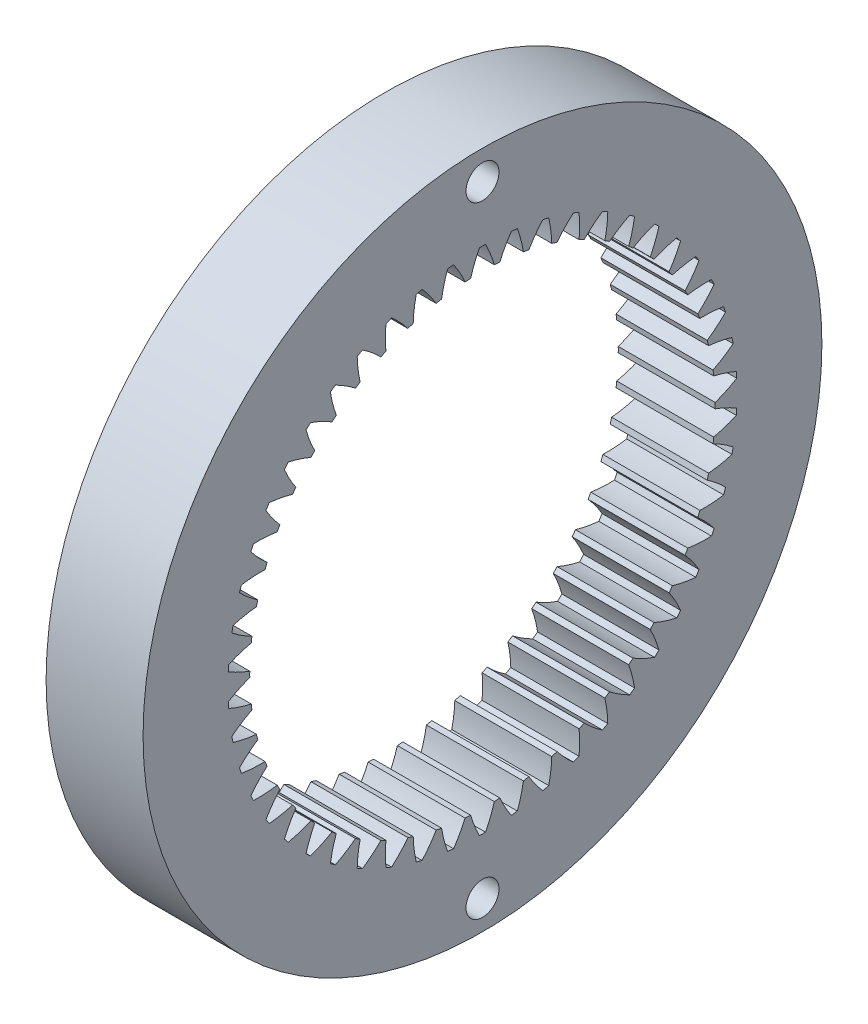
from build123d import *

# Parameters (mm, degrees)
BASPROSKE_W           = 10
BASPROSKE_H           = 11
TOOTHCUT_DEPTH        = 51.497524692
TEETHCUTS_COUNT       = 50
CROQUIS2_R            = 1.7
CORTAR_EXTRUIR1_DEPTH = 10


with BuildPart() as part:
    # BasProSke → Base-Revolve (revolve)
    with BuildSketch(Plane(origin=(0, 0, 0), x_dir=(1, 0, 0), z_dir=(0, 1, 0)), mode=Mode.PRIVATE) as base_revolve_sk:
        with Locations((5, 29.5)):
            Rectangle(BASPROSKE_W, BASPROSKE_H)
    revolve(base_revolve_sk.sketch.rotate(Axis((-10, 0, 0), (1, 0, 0)), 180), axis=Axis((-10, 0, 0), (1, 0, 0)))

    # TooCutSke → ToothCut (cut, through all)
    with BuildSketch(Plane(origin=(0, 0, 0), x_dir=(0, 0, -1), z_dir=(1, 0, 0))):
        with BuildLine():
            ThreePointArc((1.228249008, 23.943116955), (0.8277994, 25.118901547), (0.312635126, 26.249138277))
            ThreePointArc((0.312635126, 26.249138277), (0, 26.251), (-0.312635126, 26.249138277))
            ThreePointArc((-0.312635126, 26.249138277), (-0.8277994, 25.118901547), (-1.228249008, 23.943116955))
            ThreePointArc((-1.228249008, 23.943116955), (0, 23.9746), (1.228249008, 23.943116955))
        make_face()
    toothcut = extrude(amount=TOOTHCUT_DEPTH, mode=Mode.SUBTRACT)

    # TeethCuts: ToothCut ×50 about axis
    teethcuts_axis = Axis((0, 0, 0), (1, 0, 0))
    for i in range(1, TEETHCUTS_COUNT):
        add(toothcut.rotate(teethcuts_axis, i * 360 / TEETHCUTS_COUNT), mode=Mode.SUBTRACT)

    # Croquis2 → Cortar-Extruir1 (cut)
    with BuildSketch(Plane.ZY):
        with Locations((0, -32)):
            Circle(CROQUIS2_R)
        with Locations((0, 32)):
            Circle(CROQUIS2_R)
    extrude(amount=-CORTAR_EXTRUIR1_DEPTH, mode=Mode.SUBTRACT)


solid = part.part
